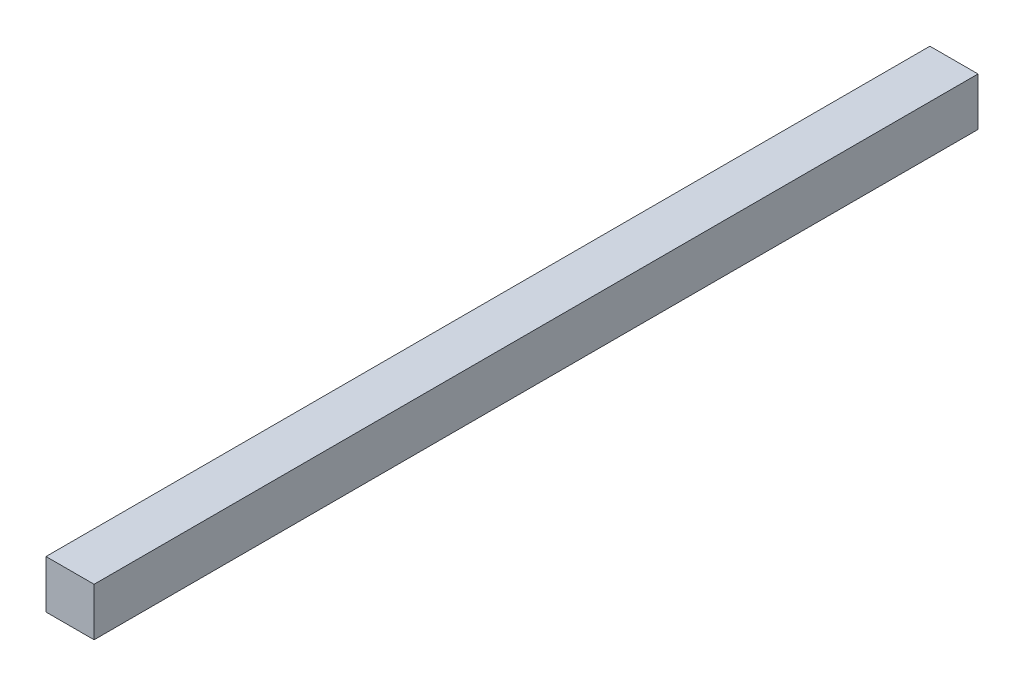
from build123d import *

# Parameters (mm, degrees)
SKETCH1_W           = 3.175
SKETCH1_H           = 3.175
BOSS_EXTRUDE1_DEPTH = 58.35


with BuildPart() as part:
    # Sketch1 → Boss-Extrude1 (new body)
    with BuildSketch(Plane.XY):
        with Locations((1.5875, 1.5875)):
            Rectangle(SKETCH1_W, SKETCH1_H)
    extrude(amount=BOSS_EXTRUDE1_DEPTH)


solid = part.part
